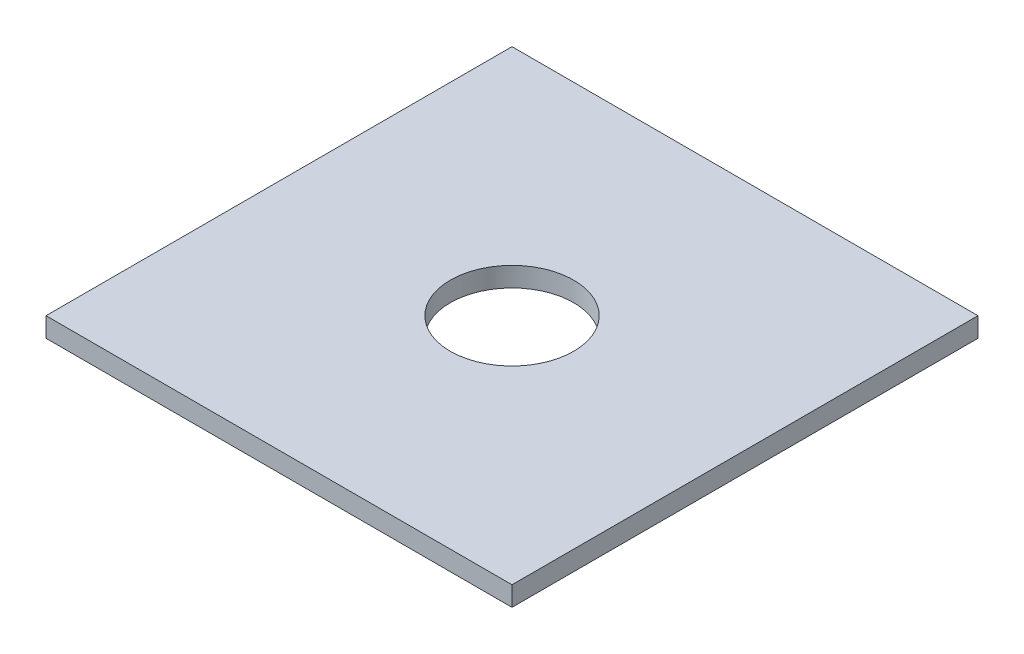
from build123d import *

# Parameters (mm, degrees)
SKETCH1_W           = 238
SKETCH1_H           = 238
SKETCH1_R           = 31.5
BOSS_EXTRUDE1_DEPTH = 10


with BuildPart() as part:
    # Sketch1 → Boss-Extrude1 (new body)
    with BuildSketch(Plane(origin=(0, 0, 0), x_dir=(1, 0, 0), z_dir=(0, 1, 0))):
        Rectangle(SKETCH1_W, SKETCH1_H)
        Circle(SKETCH1_R, mode=Mode.SUBTRACT)
    extrude(amount=BOSS_EXTRUDE1_DEPTH)


solid = part.part
